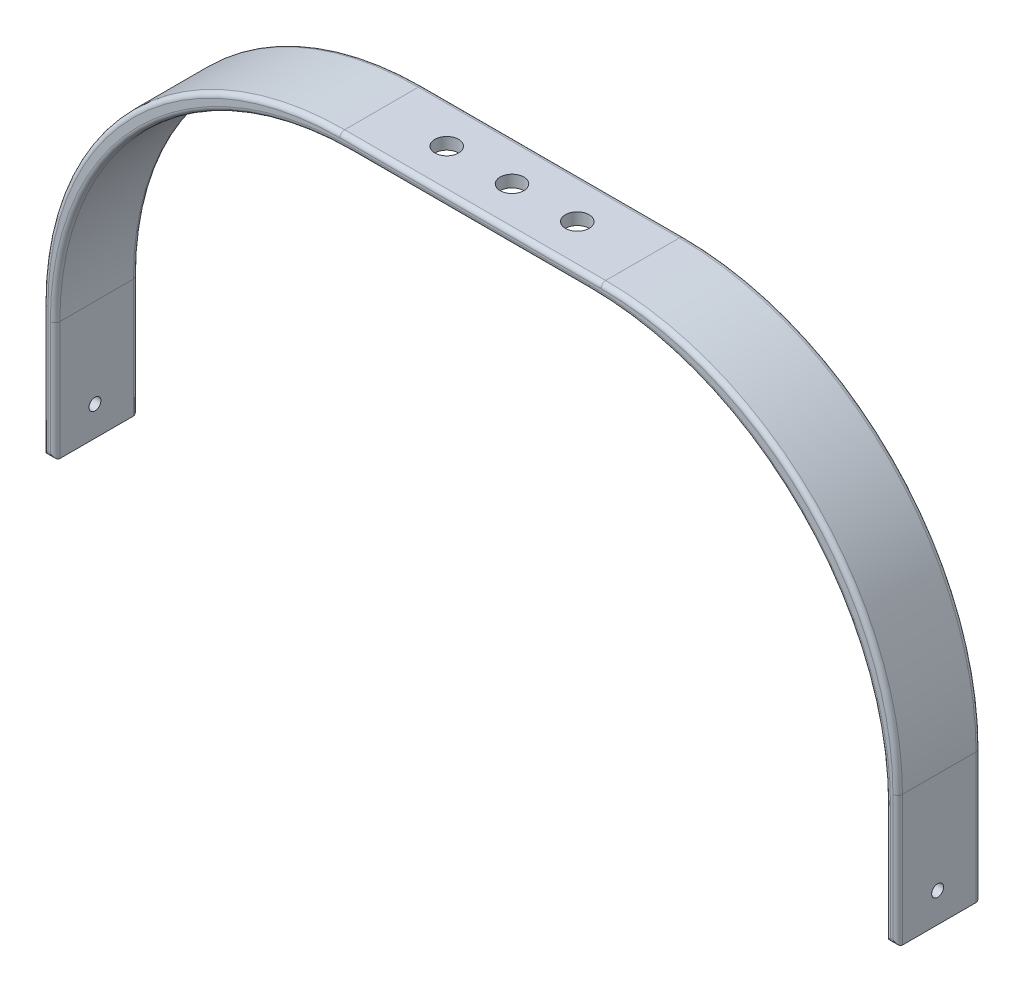
from build123d import *

# Parameters (mm, degrees)
BOSS_EXTRUDE1_DEPTH = 70
SKETCH2_R           = 5
CUT_EXTRUDE1_DEPTH  = 816
SKETCH3_R           = 10
CUT_EXTRUDE2_DEPTH  = 143
FILLET1_R           = 4


with BuildPart() as part:
    # Sketch1 → Boss-Extrude1 (new body)
    with BuildSketch(Plane.XY):
        with BuildLine():
            Line((-110, 0), (90, 0))
            ThreePointArc((90, 0), (266.776695297, -73.223304703), (340, -250))
            Line((340, -250), (340, -350))
            Line((340, -350), (350, -350))
            Line((350, -350), (350, -240))
            ThreePointArc((350, -240), (276.776695297, -63.223304703), (100, 10))
            Line((100, 10), (-120, 10))
            ThreePointArc((-120, 10), (-296.776695297, -63.223304703), (-370, -240))
            Line((-370, -240), (-370, -350))
            Line((-370, -350), (-360, -350))
            Line((-360, -350), (-360, -250))
            ThreePointArc((-360, -250), (-286.776695297, -73.223304703), (-110, 0))
        make_face()
    extrude(amount=BOSS_EXTRUDE1_DEPTH)

    # Sketch2 → Cut-Extrude1 (cut)
    with BuildSketch(Plane(origin=(350, 0, 0), x_dir=(0, 0, -1), z_dir=(1, 0, 0))):
        with Locations((-36.389856075, -325)):
            Circle(SKETCH2_R)
    extrude(amount=-CUT_EXTRUDE1_DEPTH, mode=Mode.SUBTRACT)

    # Sketch3 → Cut-Extrude2 (cut)
    with BuildSketch(Plane(origin=(0, 10, 0), x_dir=(1, 0, 0), z_dir=(0, 1, 0))):
        with Locations((-65, -35)):
            Circle(SKETCH3_R)
        with Locations((-10, -35)):
            Circle(SKETCH3_R)
        with Locations((45, -35)):
            Circle(SKETCH3_R)
    extrude(amount=-CUT_EXTRUDE2_DEPTH, mode=Mode.SUBTRACT)

    # Fillet1
    fillet1_edges = [part.edges().sort_by_distance(p)[0] for p in [
        (-296.776695297, -63.223304703, 70),
        (350, -295, 0),
        (345, -350, 0),
        (340, -300, 0),
        (266.776695297, -73.223304703, 0),
        (-10, 0, 0),
        (-286.776695297, -73.223304703, 0),
        (-370, -295, 70),
        (-360, -300, 0),
        (-365, -350, 0),
        (-370, -295, 0),
        (-296.776695297, -63.223304703, 0),
        (-10, 10, 0),
        (276.776695297, -63.223304703, 0),
        (-365, -350, 70),
        (-360, -300, 70),
        (-286.776695297, -73.223304703, 70),
        (-10, 0, 70),
        (266.776695297, -73.223304703, 70),
        (340, -300, 70),
        (345, -350, 70),
        (350, -295, 70),
        (276.776695297, -63.223304703, 70),
        (-10, 10, 70),
    ]]
    fillet(fillet1_edges, radius=FILLET1_R)


solid = part.part
